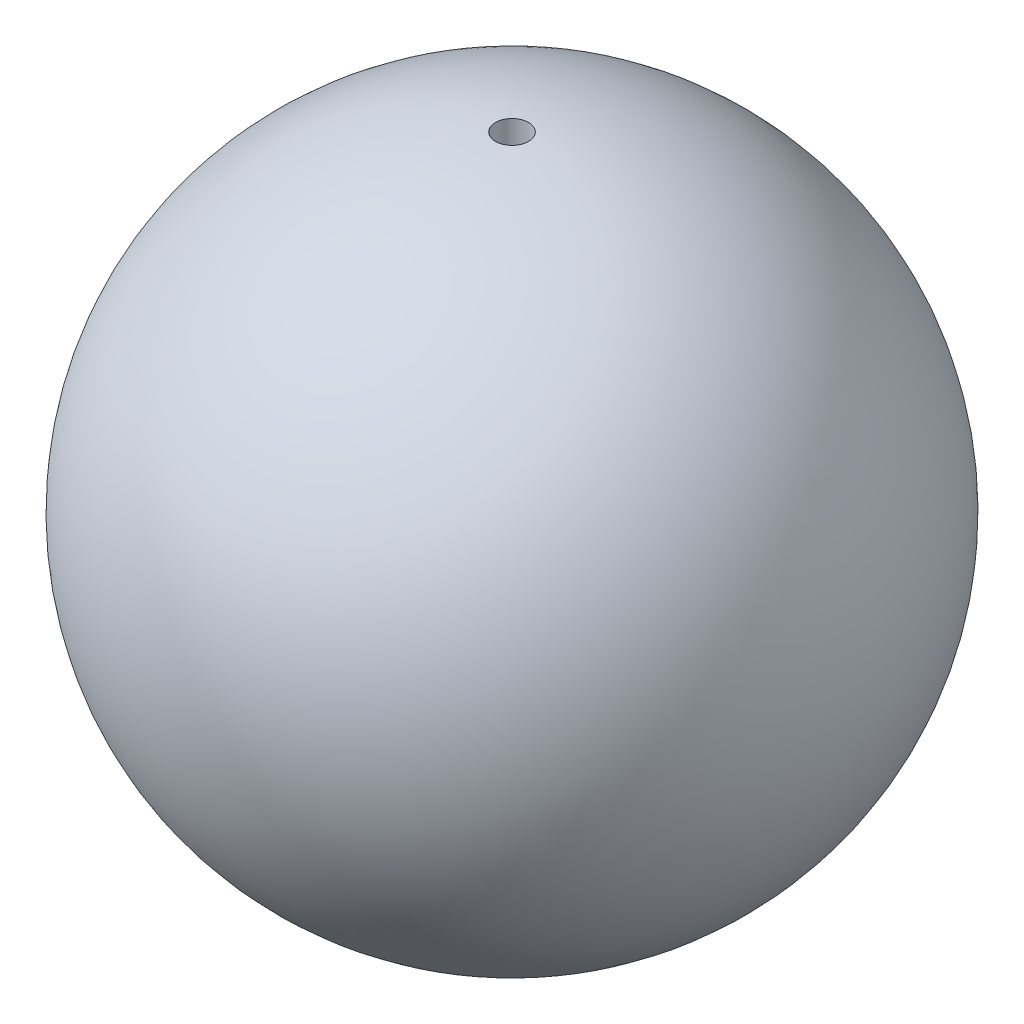
from build123d import *

# Parameters (mm, degrees)
SKETCH2_R      = 0.625
EXTRUDE1_DEPTH = 26


with BuildPart() as part:
    # Sketch1 → Revolve5 (revolve)
    with BuildSketch(Plane(origin=(0, 0, 0), x_dir=(1, 0, 0), z_dir=(0, 1, 0))):
        with BuildLine():
            Line((-12.5, 0), (12.5, 0))
            ThreePointArc((12.5, 0), (0, -12.5), (-12.5, 0))
        make_face()
    revolve(axis=Axis((-15.876321695, 0, 0), (1, 0, 0)))

    # Sketch2 → Extrude1 (cut, through all)
    with BuildSketch(Plane(origin=(0, 12.5, 0), x_dir=(-1, 0, 0), z_dir=(0, 1, 0))):
        Circle(SKETCH2_R)
    extrude(amount=-EXTRUDE1_DEPTH, mode=Mode.SUBTRACT)


solid = part.part
